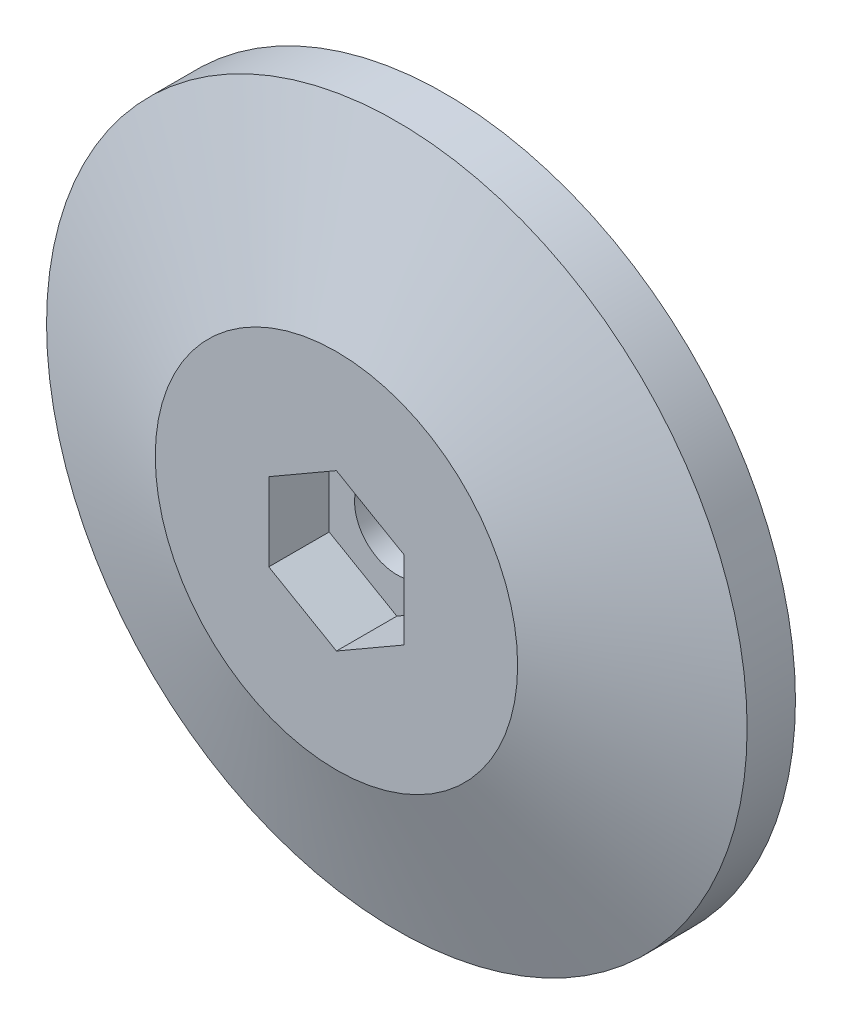
from build123d import *

# Parameters (mm, degrees)
SKETCH_1_R          = 14.5
EXTRUDE_1_DEPTH     = 2
SKETCH_2_R          = 7.5
CUT_EXTRUDE_2_DEPTH = 2.5
SKETCH_1_4_R        = 1.75
CUT_EXTRUDE_1_DEPTH = 2.8


with BuildPart() as part:
    # Эскиз1 → Бобышка-Вытянуть1 (new body)
    with BuildSketch(Plane.XY):
        Circle(SKETCH_1_R)
    extrude(amount=EXTRUDE_1_DEPTH)

    # Эскиз2 → section 1 of loft_1
    with BuildSketch(Plane.XY.offset(4.5), mode=Mode.PRIVATE) as loft_1_s1:
        Circle(SKETCH_2_R)
    # loft from a face of the part (loft_1)
    loft([part.faces().sort_by_distance((0, 0, 2))[0], loft_1_s1.sketch])

    # Эскиз2<4> → Вырез-Вытянуть2 (cut)
    with BuildSketch(Plane.XY.offset(4.5)):
        Polygon((0, 3.233161507), (-2.8, 1.616580754), (-2.8, -1.616580754), (0, -3.233161507), (2.8, -1.616580754), (2.8, 1.616580754), align=None)
    extrude(amount=-CUT_EXTRUDE_2_DEPTH, mode=Mode.SUBTRACT)

    # Эскиз1<4> → Вырез-Вытянуть1 (cut)
    with BuildSketch(Plane.XY):
        Circle(SKETCH_1_4_R)
    extrude(amount=CUT_EXTRUDE_1_DEPTH, mode=Mode.SUBTRACT)


solid = part.part
